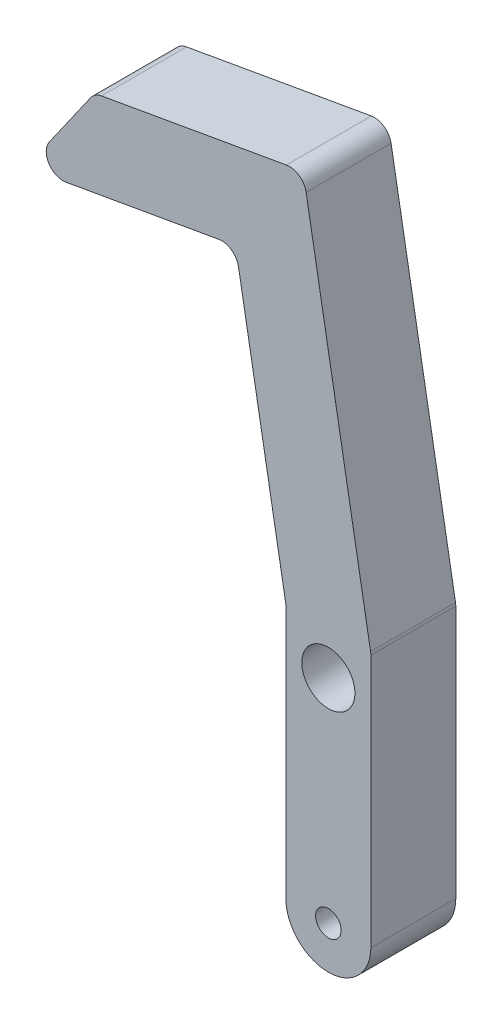
from build123d import *

# Parameters (mm, degrees)
SKETCH1_R           = 3.96875
SKETCH1_R_2         = 1.905
BOSS_EXTRUDE1_DEPTH = 12.7
FILLET1_R           = 2.54


with BuildPart() as part:
    # Sketch1 → Boss-Extrude1 (new body)
    with BuildSketch(Plane.XY):
        with BuildLine():
            Line((-6.35, -31.75), (-6.35, 6.35))
            Line((-6.35, 6.35), (-13.877185568, 49.038790666))
            Line((-13.877185568, 49.038790666), (-45.239836887, 43.508709052))
            Line((-45.239836887, 43.508709052), (-34.93811028, 58.221099372))
            Line((-34.93811028, 58.221099372), (-3.765469283, 63.71767704))
            Line((-3.765469283, 63.71767704), (6.35, 6.35))
            Line((6.35, 6.35), (6.35, -31.75))
            ThreePointArc((6.35, -31.75), (0, -38.1), (-6.35, -31.75))
        make_face()
        Circle(SKETCH1_R, mode=Mode.SUBTRACT)
        with Locations((0, -31.75)):
            Circle(SKETCH1_R_2, mode=Mode.SUBTRACT)
    extrude(amount=BOSS_EXTRUDE1_DEPTH)

    # Fillet1
    fillet1_edges = [part.edges().sort_by_distance(p)[0] for p in [
        (-6.35, 6.35, 6.35),
        (-13.877185568, 49.038790666, 6.35),
        (-45.239836887, 43.508709052, 6.35),
        (-34.93811028, 58.221099372, 6.35),
        (-3.765469283, 63.71767704, 6.35),
        (6.35, 6.35, 6.35),
    ]]
    fillet(fillet1_edges, radius=FILLET1_R)


solid = part.part
